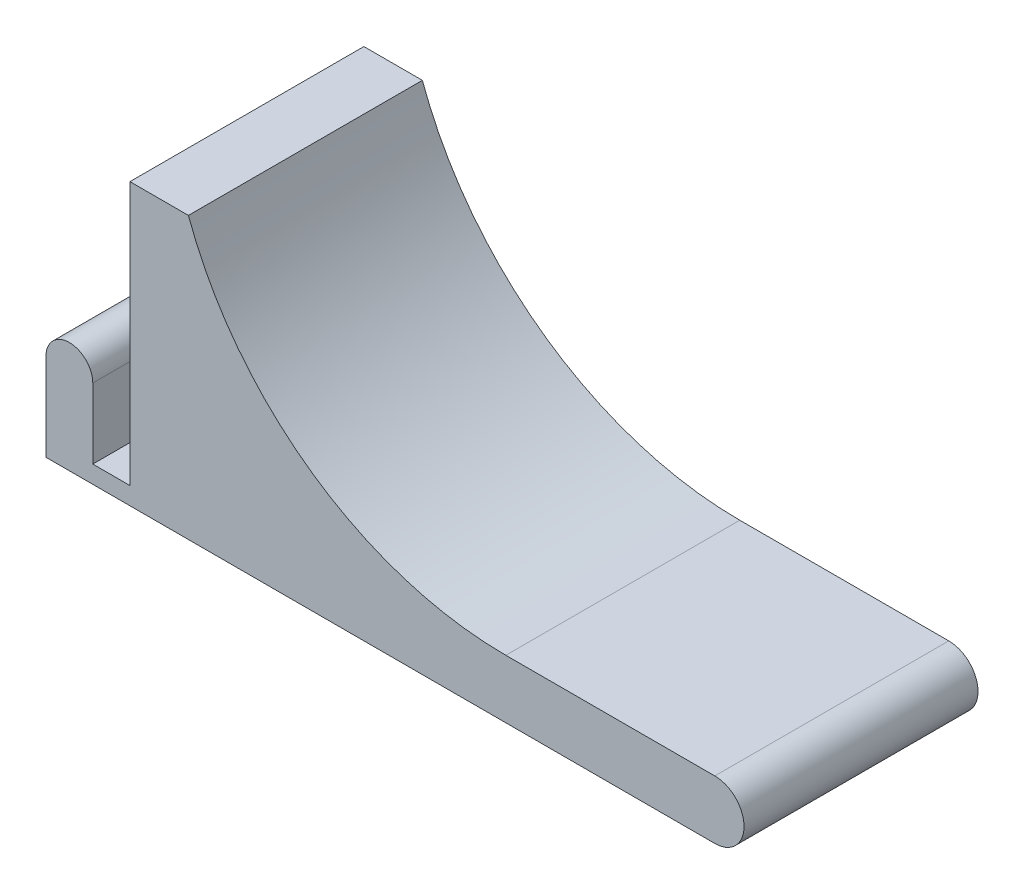
from build123d import *

# Parameters (mm, degrees)
BOSS_EXTRUDE1_DEPTH = 40


with BuildPart() as part:
    # Sketch1 → Boss-Extrude1 (new body)
    with BuildSketch(Plane.XY):
        with BuildLine():
            Line((0, 15), (0, 0))
            Line((0, 0), (114.35, 0))
            ThreePointArc((114.35, 0), (119.35, 5), (114.35, 10))
            Line((114.35, 10), (78.619624256, 10))
            ThreePointArc((78.619624256, 10), (45.494135139, 20.4444266), (24.35, 48))
            Line((24.35, 48), (14.35, 48))
            Line((14.35, 48), (14.35, 3))
            Line((14.35, 3), (8, 3))
            Line((8, 3), (8, 15))
            ThreePointArc((8, 15), (4, 19), (0, 15))
        make_face()
    extrude(amount=BOSS_EXTRUDE1_DEPTH)


solid = part.part
